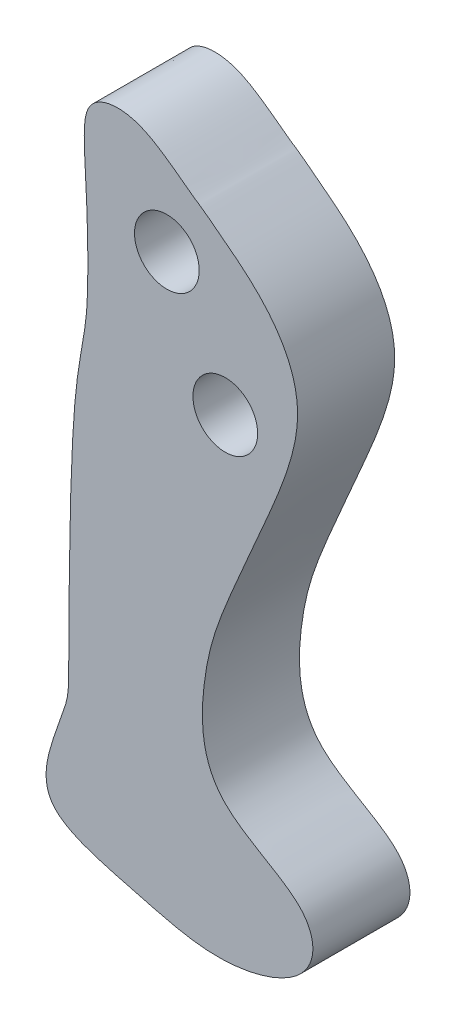
from build123d import *

# Parameters (mm, degrees)
SKETCH1_R           = 1
BOSS_EXTRUDE1_DEPTH = 3


with BuildPart() as part:
    # Sketch1 → Boss-Extrude1 (new body)
    with BuildSketch(Plane.XY):
        with BuildLine():
            add(Edge.make_bspline(
                [(-9.393609799, -8.566128575), (-9.314612984, -8.616001191), (-9.082794547, -8.786792489), (-7.763767559, -9.8061618), (-5.563524674, -11.825053856), (-7.497353203, -16.443724325), (-8.604463307, -18.888413583), (-9.316741846, -20.935694708), (-9.363636228, -24.352703962), (-5.751821781, -25.604203193), (-5.745410243, -27.847486585), (-8.686893322, -28.690404077), (-11.599998754, -27.878219868), (-14.534010878, -27.183706608), (-13.378812885, -23.396640497), (-13.433103896, -24.349514936), (-13.356554421, -15.393114972), (-13.085118516, -14.892994801), (-12.790400557, -12.726803342), (-12.855645727, -9.423167819), (-13.090710586, -7.461665319), (-11.578293098, -7.066265003), (-10.191215884, -7.951316438), (-9.542272527, -8.485467842), (-9.413807413, -8.553377328), (-9.393609799, -8.566128575)],
                knots=[0, 0, 0, 0, 0.050899026, 0.061631426, 0.107324001, 0.135996296, 0.171720829, 0.202520578, 0.228308465, 0.25224003, 0.273406738, 0.297554423, 0.312974129, 0.334313394, 0.353622681, 0.411231536, 0.432127031, 0.557323145, 0.577557216, 0.634467743, 0.705774907, 0.773430635, 0.869863246, 0.986986325, 1, 1, 1, 1], degree=3))
        make_face()
        with Locations((-10.383335194, -10.339583407)):
            Circle(SKETCH1_R, mode=Mode.SUBTRACT)
        with Locations((-8.577819206, -13.800988905)):
            Circle(SKETCH1_R, mode=Mode.SUBTRACT)
    extrude(amount=BOSS_EXTRUDE1_DEPTH)


solid = part.part
